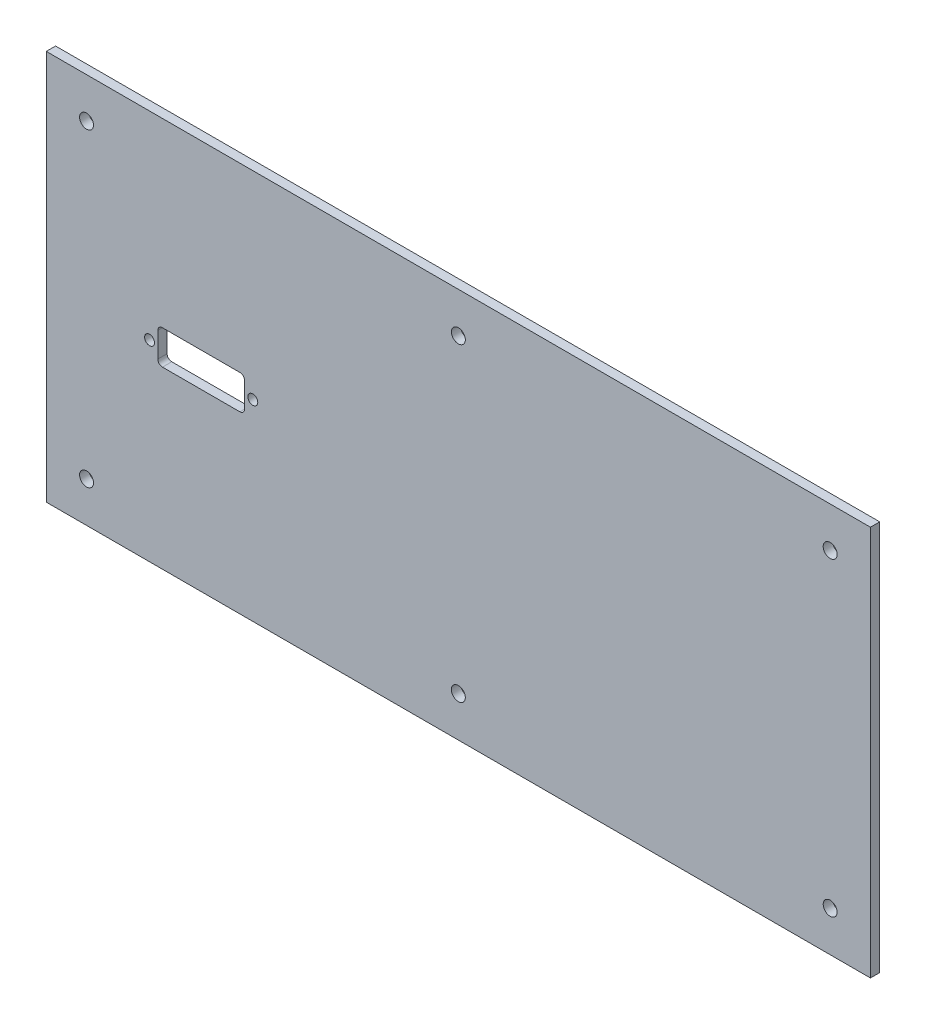
from build123d import *

# Parameters (mm, degrees)
SKETCH_1_W          = 266
SKETCH_1_H          = 126
EXTRUDE_1_DEPTH     = 3
SKETCH_2_R          = 2.25
CUT_EXTRUDE_1_DEPTH = 4
SKETCH1_R           = 1.6
CUT_EXTRUDE1_DEPTH  = 4


with BuildPart() as part:
    # Эскиз1 → Бобышка-Вытянуть1 (new body)
    with BuildSketch(Plane.XY.offset(236)):
        with Locations((-110, 60)):
            Rectangle(SKETCH_1_W, SKETCH_1_H)
    extrude(amount=EXTRUDE_1_DEPTH)

    # Эскиз2 → Вырез-Вытянуть1 (cut, through all)
    with BuildSketch(Plane.XY.offset(239)):
        with Locations((-230, 110)):
            Circle(SKETCH_2_R)
        with Locations((-110, 110)):
            Circle(SKETCH_2_R)
        with Locations((10, 110)):
            Circle(SKETCH_2_R)
        with Locations((10, 10)):
            Circle(SKETCH_2_R)
        with Locations((-110, 10)):
            Circle(SKETCH_2_R)
        with Locations((-230, 10)):
            Circle(SKETCH_2_R)
    extrude(amount=-CUT_EXTRUDE_1_DEPTH, mode=Mode.SUBTRACT)

    # Sketch1 → Cut-Extrude1 (cut, through all)
    with BuildSketch(Plane.XY.offset(239)):
        with Locations((-209.66, 59)):
            Circle(SKETCH1_R)
        with Locations((-176.34, 59)):
            Circle(SKETCH1_R)
        with BuildLine():
            Line((-207, 63), (-207, 55))
            ThreePointArc((-207, 55), (-206.560660172, 53.939339828), (-205.5, 53.5))
            Line((-205.5, 53.5), (-180.5, 53.5))
            ThreePointArc((-180.5, 53.5), (-179.439339828, 53.939339828), (-179, 55))
            Line((-179, 55), (-179, 63))
            ThreePointArc((-179, 63), (-179.439339828, 64.060660172), (-180.5, 64.5))
            Line((-180.5, 64.5), (-205.5, 64.5))
            ThreePointArc((-205.5, 64.5), (-206.560660172, 64.060660172), (-207, 63))
        make_face()
    extrude(amount=-CUT_EXTRUDE1_DEPTH, mode=Mode.SUBTRACT)


solid = part.part
